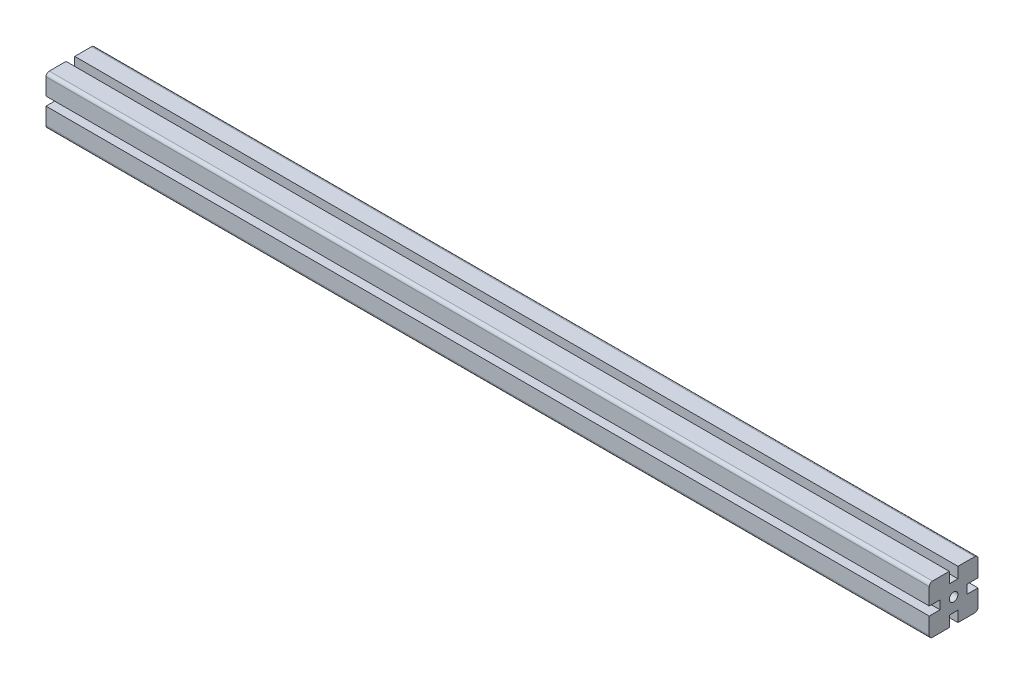
from build123d import *

# Parameters (mm, degrees)
ESQUISSE1_R        = 4
BOSS_EXTRU_1_DEPTH = 815
CONG_1_R           = 3


with BuildPart() as part:
    # Esquisse1 → Boss.-Extru.1 (new body)
    with BuildSketch(Plane(origin=(1000, 0, 0), x_dir=(0, 0, -1), z_dir=(1, 0, 0))):
        Polygon((22.5, -4), (12.5, -4), (12.5, 4), (22.5, 4), (22.5, 22.5), (4, 22.5), (4, 12.5), (-4, 12.5), (-4, 22.5), (-22.5, 22.5), (-22.5, 4), (-12.5, 4), (-12.5, -4), (-22.5, -4), (-22.5, -22.5), (-4, -22.5), (-4, -12.5), (4, -12.5), (4, -22.5), (22.5, -22.5), align=None)
        Circle(ESQUISSE1_R, mode=Mode.SUBTRACT)
    extrude(amount=-BOSS_EXTRU_1_DEPTH)

    # Congé1
    cong_1_edges = [part.edges().sort_by_distance(p)[0] for p in [
        (592.5, -22.5, -22.5),
        (592.5, 22.5, -22.5),
        (592.5, -22.5, 22.5),
        (592.5, 22.5, 22.5),
    ]]
    fillet(cong_1_edges, radius=CONG_1_R)


solid = part.part
